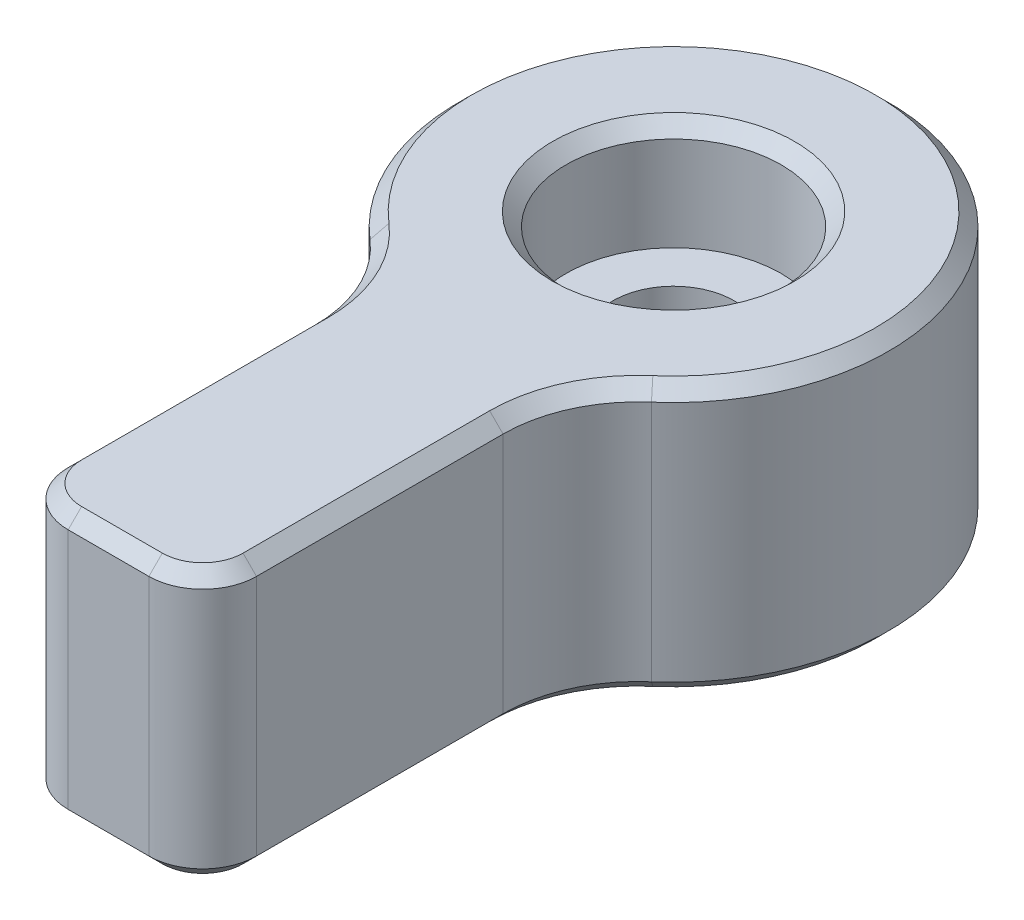
from build123d import *

# Parameters (mm, degrees)
EXTRUDE_1_DEPTH             = 10
HOLE_WIZARD_M41_D           = 4.5
HOLE_WIZARD_M41_CBORE_D     = 8
HOLE_WIZARD_M41_CBORE_DEPTH = 4
FILLET_1_R                  = 2
FILLET_2_R                  = 5
CHAMFER_1_SIZE              = 0.5


with BuildPart() as part:
    # Эскиз1 → Бобышка-Вытянуть1 (new body)
    with BuildSketch(Plane(origin=(0, 0, 0), x_dir=(1, 0, 0), z_dir=(0, 1, 0))):
        with BuildLine():
            Line((-3.5, -7.193747285), (-3.5, -21))
            Line((-3.5, -21), (3.5, -21))
            Line((3.5, -21), (3.5, -7.193747285))
            ThreePointArc((3.5, -7.193747285), (0, 8), (-3.5, -7.193747285))
        make_face()
    extrude(amount=EXTRUDE_1_DEPTH)

    # Цековка для винта с внутренним шестигранником M41 (through all)
    with Locations(Plane(origin=(0, 10, 0), x_dir=(1, 0, 0), z_dir=(0, 1, 0))):
        with Locations((0, 0)):
            CounterBoreHole(HOLE_WIZARD_M41_D / 2, HOLE_WIZARD_M41_CBORE_D / 2, HOLE_WIZARD_M41_CBORE_DEPTH)

    # Скругление1
    fillet_1_edges = [part.edges().sort_by_distance(p)[0] for p in [
        (3.5, 5, 21),
        (-3.5, 5, 21),
    ]]
    fillet(fillet_1_edges, radius=FILLET_1_R)

    # Скругление2
    fillet_2_edges = [part.edges().sort_by_distance(p)[0] for p in [
        (-3.5, 5, 7.193747285),
        (3.5, 5, 7.193747285),
    ]]
    fillet(fillet_2_edges, radius=FILLET_2_R)

    # Фаска1
    chamfer_1_edges = [part.edges().sort_by_distance(p)[0] for p in [
        (-4, 10, 0),
        (2.25, 0, 0),
        (3.5, 0, 14.418078893),
        (3.5, 10, 14.418078893),
        (0, 0, 21),
        (-2.914213562, 0, 20.414213562),
        (2.914213562, 0, 20.414213562),
        (0, 10, 21),
        (-2.914213562, 10, 20.414213562),
        (2.914213562, 10, 20.414213562),
        (0, 0, -8),
        (0, 10, -8),
        (-3.5, 0, 14.418078893),
        (-3.5, 10, 14.418078893),
        (3.953234455, 0, 7.756032051),
        (3.953234455, 10, 7.756032051),
        (-3.953234455, 0, 7.756032051),
        (-3.953234455, 10, 7.756032051),
    ]]
    chamfer(chamfer_1_edges, length=CHAMFER_1_SIZE)


solid = part.part
